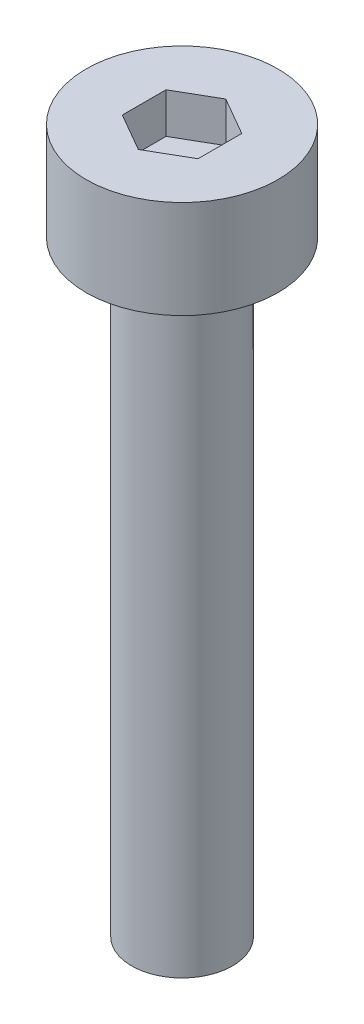
from build123d import *

# Parameters (mm, degrees)
SKETCH1_R           = 1.9
BOSS_EXTRUDE1_DEPTH = 1.94
CUT_EXTRUDE1_DEPTH  = 0.8
SKETCH3_R           = 1
BOSS_EXTRUDE2_DEPTH = 12


with BuildPart() as part:
    # Sketch1 → Boss-Extrude1 (new body)
    with BuildSketch(Plane(origin=(0, 0, 0), x_dir=(1, 0, 0), z_dir=(0, 1, 0))):
        Circle(SKETCH1_R)
    extrude(amount=BOSS_EXTRUDE1_DEPTH)

    # Sketch2 → Cut-Extrude1 (cut)
    with BuildSketch(Plane(origin=(0, 1.94, 0), x_dir=(1, 0, 0), z_dir=(0, 1, 0))):
        Polygon((0, 0.866025404), (-0.75, 0.433012702), (-0.75, -0.433012702), (0, -0.866025404), (0.75, -0.433012702), (0.75, 0.433012702), align=None)
    extrude(amount=-CUT_EXTRUDE1_DEPTH, mode=Mode.SUBTRACT)

    # Sketch3 → Boss-Extrude2 (add)
    with BuildSketch(Plane.XZ):
        Circle(SKETCH3_R)
    extrude(amount=BOSS_EXTRUDE2_DEPTH)


solid = part.part
